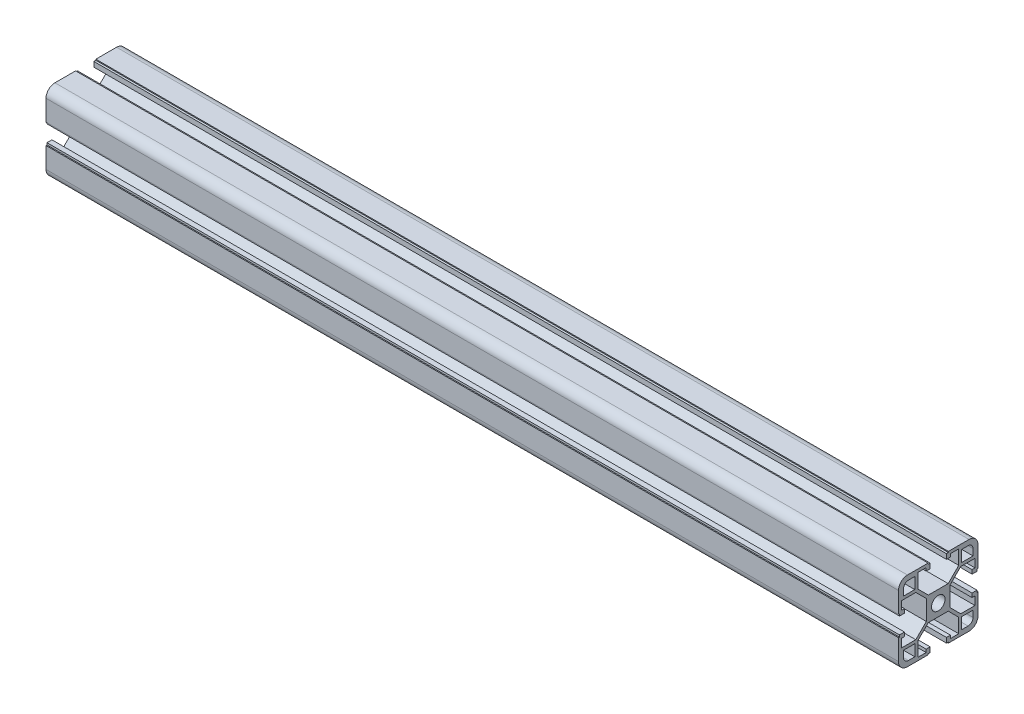
from build123d import *

# Parameters (mm, degrees)
SKETCH1_R                 = 3.4
F_40_X_40L_X_R4_5_1_DEPTH = 429


with BuildPart() as part:
    # Sketch1 → 铝型材 40 X 40L X R4.5(1) (new body)
    with BuildSketch(Plane(origin=(-12.168141593, 0, 0), x_dir=(0, 0, -1), z_dir=(1, 0, 0))):
        with BuildLine():
            Line((-5.1, 20), (-5.1, 19.5))
            Line((-5.1, 19.5), (-4.1, 19.5))
            Line((-4.1, 19.5), (-4.1, 17))
            Line((-4.1, 17), (-6.1, 17))
            Line((-6.1, 17), (-6.1, 18.5))
            Line((-6.1, 18.5), (-10.3, 18.5))
            Line((-10.3, 18.5), (-10.3, 11.3))
            Line((-10.3, 11.3), (-5, 6))
            Line((-5, 6), (5, 6))
            Line((5, 6), (10.3, 11.3))
            Line((10.3, 11.3), (10.3, 18.5))
            Line((10.3, 18.5), (6.1, 18.5))
            Line((6.1, 18.5), (6.1, 17))
            Line((6.1, 17), (4.1, 17))
            Line((4.1, 17), (4.1, 19.5))
            Line((4.1, 19.5), (5.1, 19.5))
            Line((5.1, 19.5), (5.1, 20))
            Line((5.1, 20), (15.5, 20))
            ThreePointArc((15.5, 20), (18.681980515, 18.681980515), (20, 15.5))
            Line((20, 15.5), (20, 5.1))
            Line((20, 5.1), (19.5, 5.1))
            Line((19.5, 5.1), (19.5, 4.1))
            Line((19.5, 4.1), (17, 4.1))
            Line((17, 4.1), (17, 6.1))
            Line((17, 6.1), (18.5, 6.1))
            Line((18.5, 6.1), (18.5, 10.3))
            Line((18.5, 10.3), (11.3, 10.3))
            Line((11.3, 10.3), (6, 5))
            Line((6, 5), (6, -5))
            Line((6, -5), (11.3, -10.3))
            Line((11.3, -10.3), (18.5, -10.3))
            Line((18.5, -10.3), (18.5, -6.1))
            Line((18.5, -6.1), (17, -6.1))
            Line((17, -6.1), (17, -4.1))
            Line((17, -4.1), (19.5, -4.1))
            Line((19.5, -4.1), (19.5, -5.1))
            Line((19.5, -5.1), (20, -5.1))
            Line((20, -5.1), (20, -15.5))
            ThreePointArc((20, -15.5), (18.681980515, -18.681980515), (15.5, -20))
            Line((15.5, -20), (5.1, -20))
            Line((5.1, -20), (5.1, -19.5))
            Line((5.1, -19.5), (4.1, -19.5))
            Line((4.1, -19.5), (4.1, -17))
            Line((4.1, -17), (6.1, -17))
            Line((6.1, -17), (6.1, -18.5))
            Line((6.1, -18.5), (10.3, -18.5))
            Line((10.3, -18.5), (10.3, -11.3))
            Line((10.3, -11.3), (5, -6))
            Line((5, -6), (-5, -6))
            Line((-5, -6), (-10.3, -11.3))
            Line((-10.3, -11.3), (-10.3, -18.5))
            Line((-10.3, -18.5), (-6.1, -18.5))
            Line((-6.1, -18.5), (-6.1, -17))
            Line((-6.1, -17), (-4.1, -17))
            Line((-4.1, -17), (-4.1, -19.5))
            Line((-4.1, -19.5), (-5.1, -19.5))
            Line((-5.1, -19.5), (-5.1, -20))
            Line((-5.1, -20), (-15.5, -20))
            ThreePointArc((-15.5, -20), (-18.681980515, -18.681980515), (-20, -15.5))
            Line((-20, -15.5), (-20, -5.1))
            Line((-20, -5.1), (-19.5, -5.1))
            Line((-19.5, -5.1), (-19.5, -4.1))
            Line((-19.5, -4.1), (-17, -4.1))
            Line((-17, -4.1), (-17, -6.1))
            Line((-17, -6.1), (-18.5, -6.1))
            Line((-18.5, -6.1), (-18.5, -10.3))
            Line((-18.5, -10.3), (-11.3, -10.3))
            Line((-11.3, -10.3), (-6, -5))
            Line((-6, -5), (-6, 5))
            Line((-6, 5), (-11.3, 10.3))
            Line((-11.3, 10.3), (-18.5, 10.3))
            Line((-18.5, 10.3), (-18.5, 6.1))
            Line((-18.5, 6.1), (-17, 6.1))
            Line((-17, 6.1), (-17, 4.1))
            Line((-17, 4.1), (-19.5, 4.1))
            Line((-19.5, 4.1), (-19.5, 5.1))
            Line((-19.5, 5.1), (-20, 5.1))
            Line((-20, 5.1), (-20, 15.5))
            ThreePointArc((-20, 15.5), (-18.681980515, 18.681980515), (-15.5, 20))
            Line((-15.5, 20), (-5.1, 20))
        make_face()
        Circle(SKETCH1_R, mode=Mode.SUBTRACT)
        with BuildLine():
            Line((11.8, 17.5), (15, 17.5))
            ThreePointArc((15, 17.5), (16.767766953, 16.767766953), (17.5, 15))
            Line((17.5, 15), (17.5, 11.8))
            Line((17.5, 11.8), (11.8, 11.8))
            Line((11.8, 11.8), (11.8, 17.5))
        make_face(mode=Mode.SUBTRACT)
        with BuildLine():
            Line((-15, 17.5), (-11.8, 17.5))
            Line((-11.8, 17.5), (-11.8, 11.8))
            Line((-11.8, 11.8), (-17.5, 11.8))
            Line((-17.5, 11.8), (-17.5, 15))
            ThreePointArc((-17.5, 15), (-16.767766953, 16.767766953), (-15, 17.5))
        make_face(mode=Mode.SUBTRACT)
        with BuildLine():
            Line((-17.5, -11.8), (-11.8, -11.8))
            Line((-11.8, -11.8), (-11.8, -17.5))
            Line((-11.8, -17.5), (-15, -17.5))
            ThreePointArc((-15, -17.5), (-16.767766953, -16.767766953), (-17.5, -15))
            Line((-17.5, -15), (-17.5, -11.8))
        make_face(mode=Mode.SUBTRACT)
        with BuildLine():
            Line((11.8, -11.8), (17.5, -11.8))
            Line((17.5, -11.8), (17.5, -15))
            ThreePointArc((17.5, -15), (16.767766953, -16.767766953), (15, -17.5))
            Line((15, -17.5), (11.8, -17.5))
            Line((11.8, -17.5), (11.8, -11.8))
        make_face(mode=Mode.SUBTRACT)
    extrude(amount=F_40_X_40L_X_R4_5_1_DEPTH)


solid = part.part
